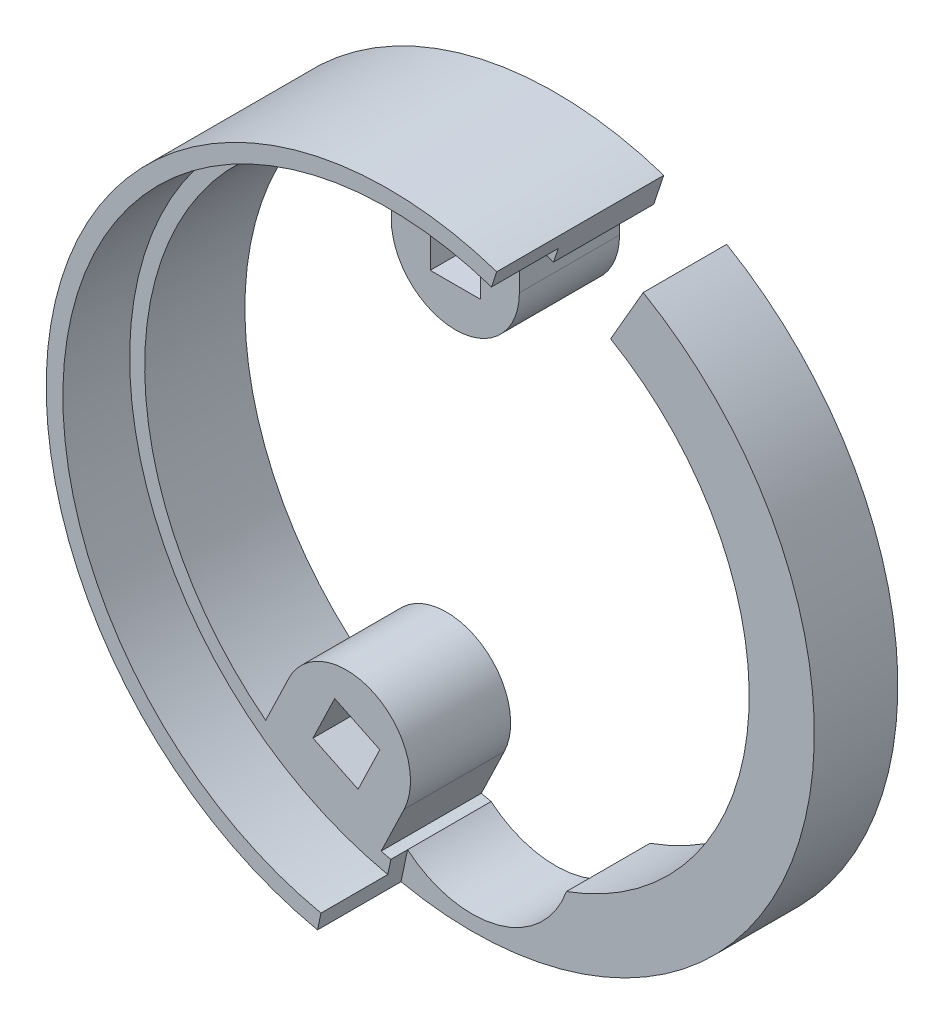
from build123d import *

# Parameters (mm, degrees)
RESSALTO_EXTRUS_O2_DEPTH = 6
CORTE_EXTRUS_O1_DEPTH    = 1
ESBO_O8_W                = 3
ESBO_O8_H                = 3
RESSALTO_EXTRUS_O4_DEPTH = 6
RESSALTO_EXTRUS_O5_DEPTH = 4


with BuildPart() as part:
    # Esboço4 → Ressalto-extrusão2 (new body)
    with BuildSketch(Plane.XY):
        with BuildLine():
            Line((10.25, 17.753520778), (8.3, 14.376021703))
            ThreePointArc((8.3, 14.376021703), (16.535747837, -1.45912421), (5.654249214, -15.607352941))
            ThreePointArc((5.654249214, -15.607352941), (1.575368798, -19.389491614), (-3.857534027, -18.195588235))
            ThreePointArc((-3.857534027, -18.195588235), (-17.949080324, 4.877552207), (5.882044961, 17.645439838))
            Line((5.882044961, 17.645439838), (6.482899016, 19.447931004))
            ThreePointArc((6.482899016, 19.447931004), (-8.409235035, -18.695848901), (10.25, 17.753520778))
        make_face()
    extrude(amount=RESSALTO_EXTRUS_O2_DEPTH)

    # Esboço7 → Corte-extrusão1 (cut)
    with BuildSketch(Plane.XY.offset(6)):
        with BuildLine():
            Line((-3.857534027, -18.195588235), (-4.251583202, -20.054277356))
            ThreePointArc((-4.251583202, -20.054277356), (19.140340931, -7.341481393), (10.25, 17.753520778))
            Line((10.25, 17.753520778), (8.3, 14.376021703))
            ThreePointArc((8.3, 14.376021703), (16.535747837, -1.45912421), (5.654249214, -15.607352941))
            ThreePointArc((5.654249214, -15.607352941), (1.575368798, -19.389491614), (-3.857534027, -18.195588235))
        make_face()
    extrude(amount=-CORTE_EXTRUS_O1_DEPTH, mode=Mode.SUBTRACT)

    # Esboço8 → Ressalto-extrusão4 (add)
    with BuildSketch(Plane(origin=(0, 0, 0), x_dir=(-1, 0, 0), z_dir=(0, 0, -1))):
        with BuildLine():
            ThreePointArc((9.976510425, -11.876705547), (4.856795522, -10.085239821), (3.065329796, -15.204954723))
            Line((3.065329796, -15.204954723), (5.002459987, -19.227447012))
            Line((5.002459987, -19.227447012), (11.913640616, -15.899197835))
            Line((11.913640616, -15.899197835), (9.976510425, -11.876705547))
        make_face()
        Polygon((5.820292417, -15.543109046), (4.5186412, -12.840202442), (7.221547804, -11.538551224), (8.523199021, -14.241457828), align=None, mode=Mode.SUBTRACT)
        with BuildLine():
            ThreePointArc((-3.835415892, 15.029187597), (0, 11.193771705), (3.835415892, 15.029187597))
            Line((3.835415892, 15.029187597), (3.835415892, 19.493817211))
            Line((3.835415892, 19.493817211), (-3.835415892, 19.493817211))
            Line((-3.835415892, 19.493817211), (-3.835415892, 15.029187597))
        make_face()
        with Locations((0, 15.029187597)):
            Rectangle(ESBO_O8_W, ESBO_O8_H, mode=Mode.SUBTRACT)
    extrude(amount=-RESSALTO_EXTRUS_O4_DEPTH)

    # Esboço9 → Ressalto-extrusão5 (add)
    with BuildSketch(Plane.XY.offset(6)):
        with BuildLine():
            Line((-4.0441889, -19.076019924), (-4.251583202, -20.054277356))
            ThreePointArc((-4.251583202, -20.054277356), (-19.782588529, 5.375796787), (6.482899016, 19.447931004))
            Line((6.482899016, 19.447931004), (6.16666004, 18.499251443))
            ThreePointArc((6.16666004, 18.499251443), (-18.81758421, 5.113562798), (-4.0441889, -19.076019924))
        make_face()
    extrude(amount=RESSALTO_EXTRUS_O5_DEPTH)


solid = part.part
